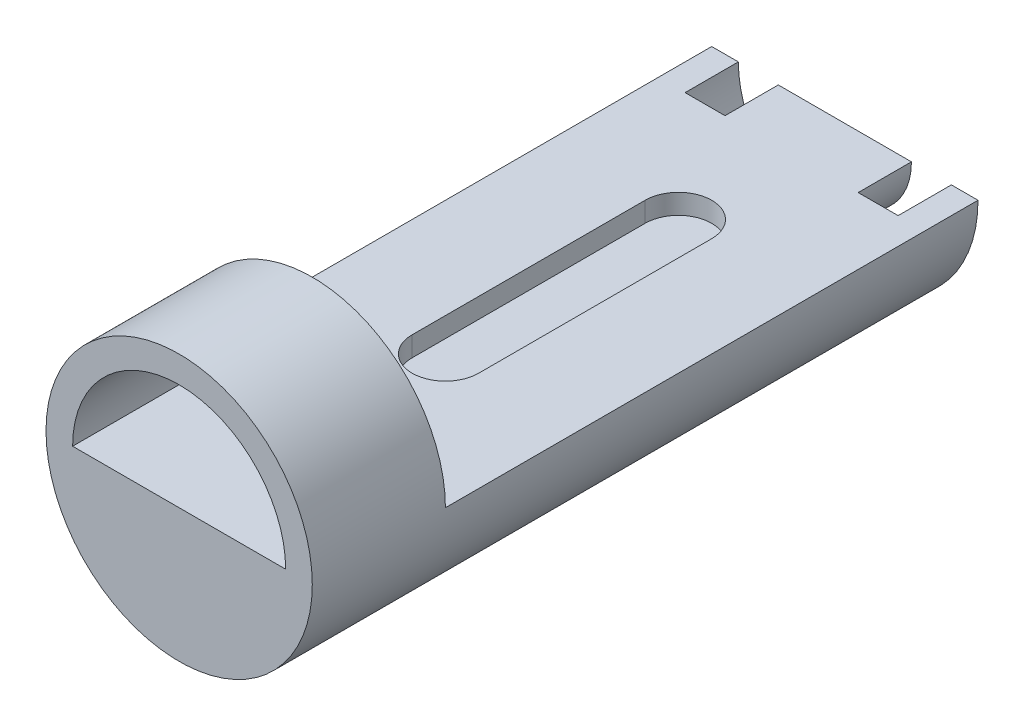
from build123d import *

# Parameters (mm, degrees)
BOSS_EXTRUDE1_DEPTH = 100
CUT_EXTRUDE1_DEPTH  = 8
CUT_EXTRUDE2_DEPTH  = 3
BOSS_EXTRUDE4_DEPTH = 20


with BuildPart() as part:
    # Sketch1 → Boss-Extrude1 (new body)
    with BuildSketch(Plane.XY):
        with BuildLine():
            Line((-20, 0), (-16, 0))
            Line((-16, 0), (-10, 0))
            Line((-10, 0), (0, 0))
            Line((0, 0), (10, 0))
            Line((10, 0), (16, 0))
            Line((16, 0), (20, 0))
            ThreePointArc((20, 0), (0, -20), (-20, 0))
        make_face()
    extrude(amount=BOSS_EXTRUDE1_DEPTH)

    # Sketch2 → Cut-Extrude1 (cut)
    with BuildSketch(Plane(origin=(0, 0, 0), x_dir=(-1, 0, 0), z_dir=(0, 0, -1))):
        with BuildLine():
            Line((-10, 0), (-16, 0))
            ThreePointArc((-16, 0), (0, -16), (16, 0))
            Line((16, 0), (10, 0))
            ThreePointArc((10, 0), (0, -10), (-10, 0))
        make_face()
    extrude(amount=-CUT_EXTRUDE1_DEPTH, mode=Mode.SUBTRACT)

    # Sketch3 → Cut-Extrude2 (cut)
    with BuildSketch(Plane(origin=(0, 0, 0), x_dir=(1, 0, 0), z_dir=(0, 1, 0))):
        with BuildLine():
            Line((5, -25), (5, -60))
            ThreePointArc((5, -60), (0, -65), (-5, -60))
            Line((-5, -60), (-5, -25))
            ThreePointArc((-5, -25), (0, -20), (5, -25))
        make_face()
    extrude(amount=-CUT_EXTRUDE2_DEPTH, mode=Mode.SUBTRACT)

    # Sketch4 → Boss-Extrude4 (add)
    with BuildSketch(Plane.XY.offset(100)):
        with BuildLine():
            Line((-20, 0), (-16, 0))
            ThreePointArc((-16, 0), (0, 16), (16, 0))
            Line((16, 0), (20, 0))
            ThreePointArc((20, 0), (0, 20), (-20, 0))
        make_face()
    extrude(amount=-BOSS_EXTRUDE4_DEPTH)


solid = part.part
